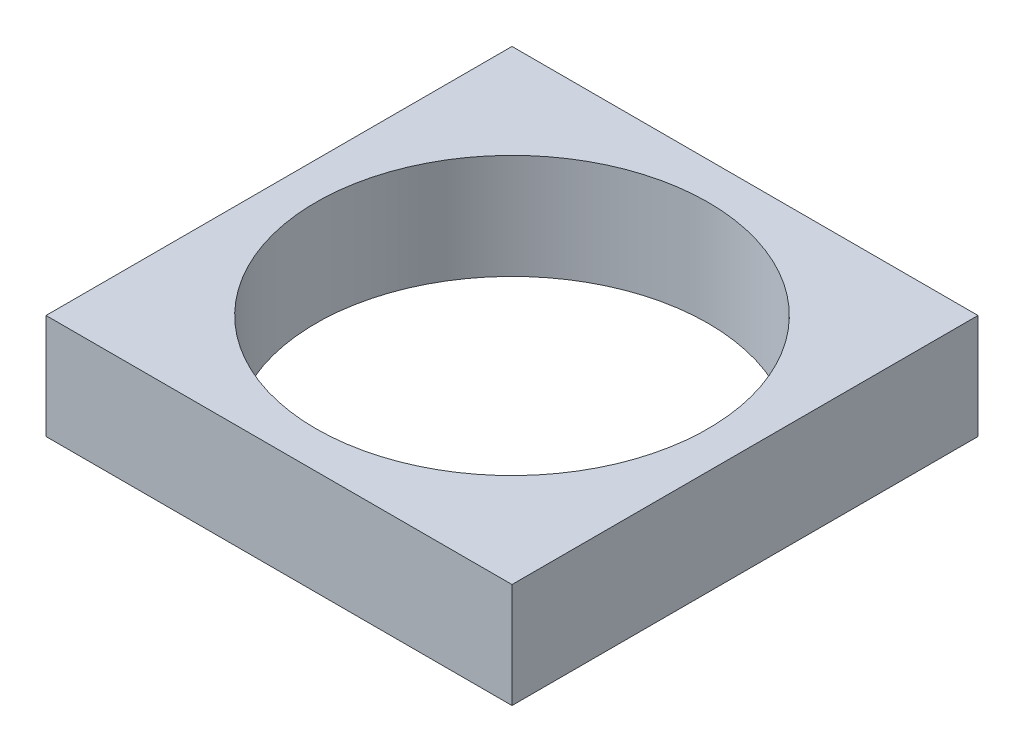
from build123d import *

# Parameters (mm, degrees)
SKETCH_1_W      = 12
SKETCH_1_H      = 12
SKETCH_1_R      = 5.05
EXTRUDE_1_DEPTH = 2.7


with BuildPart() as part:
    # 草图1 → 凸台-拉伸1 (new body)
    with BuildSketch(Plane(origin=(0, 0, 0), x_dir=(1, 0, 0), z_dir=(0, 1, 0))):
        Rectangle(SKETCH_1_W, SKETCH_1_H)
        Circle(SKETCH_1_R, mode=Mode.SUBTRACT)
    extrude(amount=EXTRUDE_1_DEPTH)


solid = part.part
